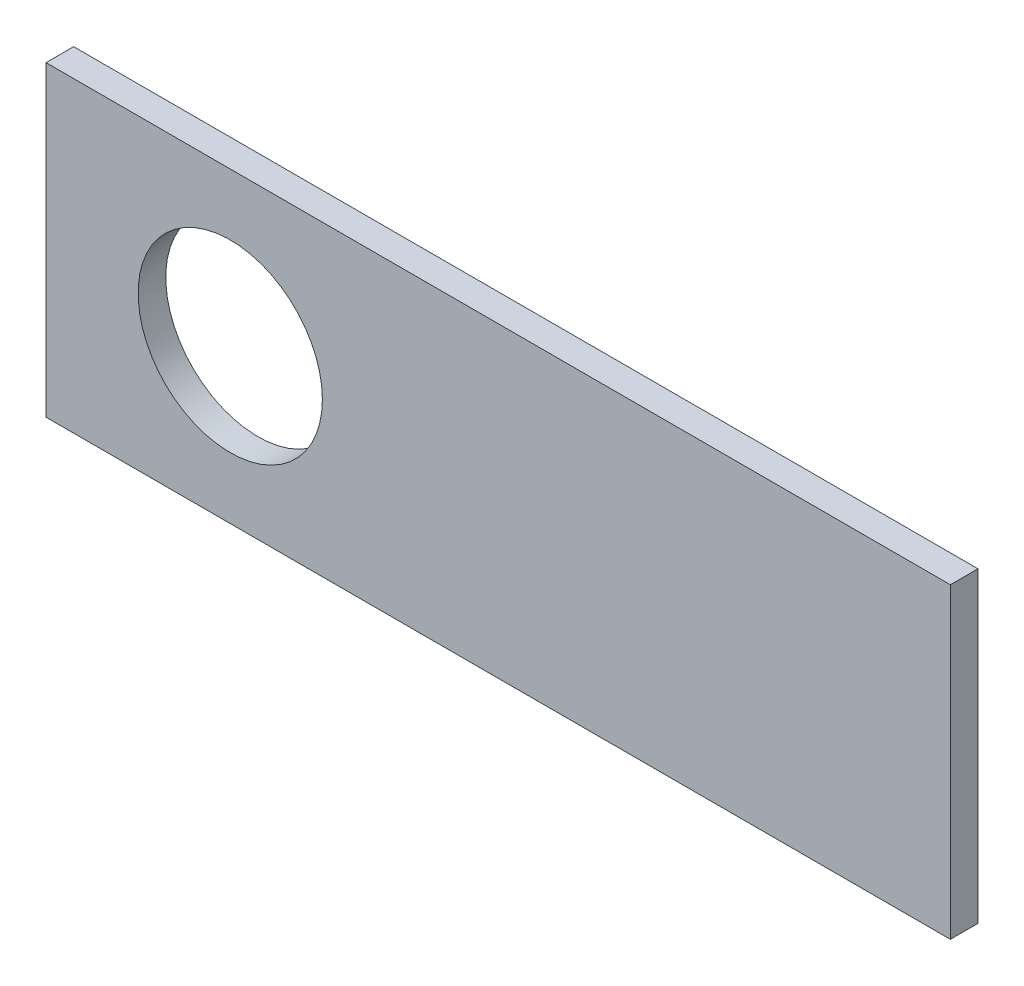
from build123d import *

# Parameters (mm, degrees)
SKETCH_1_W          = 589
SKETCH_1_H          = 200
EXTRUDE_1_DEPTH     = 18
SKETCH_2_R          = 60
CUT_EXTRUDE_1_DEPTH = 19


with BuildPart() as part:
    # Эскиз1 → Бобышка-Вытянуть1 (new body)
    with BuildSketch(Plane.XY):
        Rectangle(SKETCH_1_W, SKETCH_1_H)
    extrude(amount=EXTRUDE_1_DEPTH)

    # Эскиз2 → Вырез-Вытянуть1 (cut, through all)
    with BuildSketch(Plane.XY.offset(18)):
        with Locations((-174.5, 0)):
            Circle(SKETCH_2_R)
    extrude(amount=-CUT_EXTRUDE_1_DEPTH, mode=Mode.SUBTRACT)


solid = part.part
